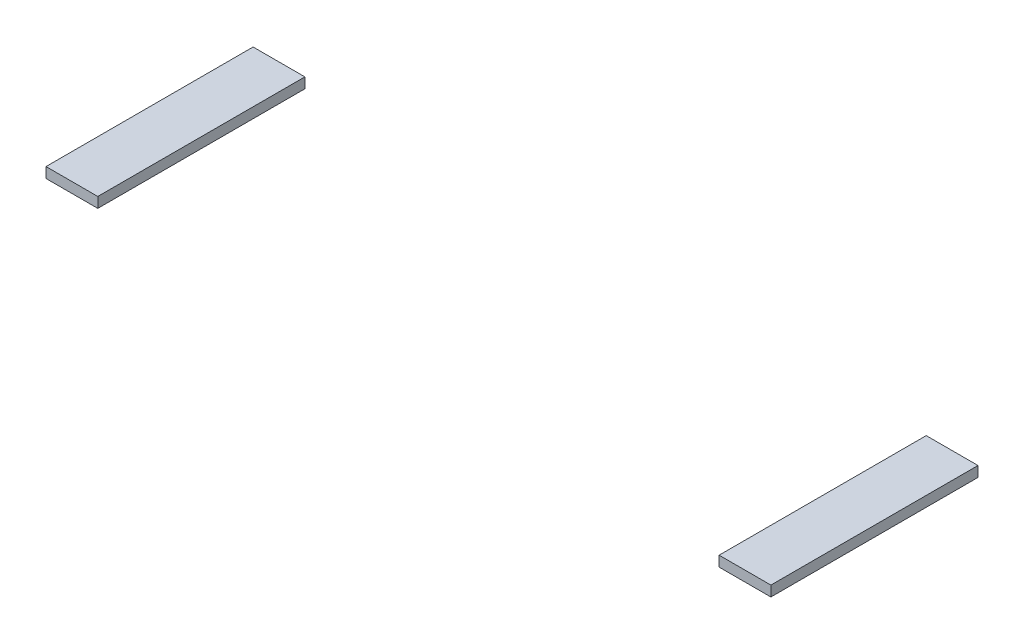
from build123d import *

# Parameters (mm, degrees)
SKETCH1_W             = 2
SKETCH1_H             = 0.4
BOSS_EXTRUDE1_DEPTH   = 8
BOSS_EXTRUDE1_2_DEPTH = 8


with BuildPart() as part:
    # Sketch1 → Boss-Extrude1 (new body)
    with BuildSketch(Plane.XY):
        with Locations((1, 0.2)):
            Rectangle(SKETCH1_W, SKETCH1_H)
    extrude(amount=BOSS_EXTRUDE1_DEPTH)


with BuildPart() as body_2:
    # Sketch1 → Boss-Extrude1 2 (new body)
    with BuildSketch(Plane.XY):
        with Locations((27, 0.2)):
            Rectangle(SKETCH1_W, SKETCH1_H)
    extrude(amount=BOSS_EXTRUDE1_2_DEPTH)


solid = Compound([part.part, body_2.part])
